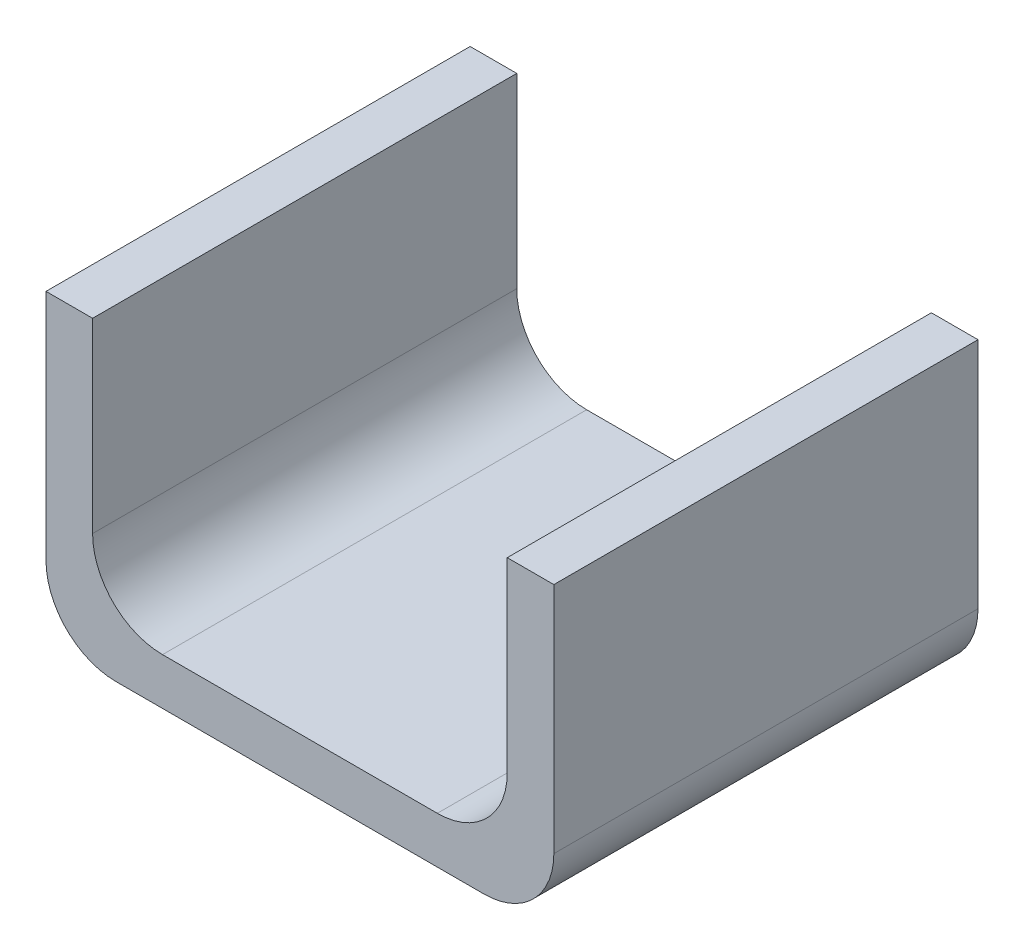
from build123d import *

# Parameters (mm, degrees)
SKETCH1_W           = 21.792403666
SKETCH1_H           = 18.201033873
BOSS_EXTRUDE1_DEPTH = 2
SKETCH1_3_W         = 2
SKETCH1_3_H         = 18.201033873
BOSS_EXTRUDE2_DEPTH = 13
FILLET1_R           = 3


with BuildPart() as part:
    # Sketch1 → Boss-Extrude1 (new body)
    with BuildSketch(Plane(origin=(0, 0, 0), x_dir=(1, 0, 0), z_dir=(0, 1, 0))):
        with Locations((-0.033894989, -2.255649147)):
            Rectangle(SKETCH1_W, SKETCH1_H)
    extrude(amount=BOSS_EXTRUDE1_DEPTH)

    # Sketch1_3 → Boss-Extrude2 (add)
    with BuildSketch(Plane(origin=(0, 0, 0), x_dir=(1, 0, 0), z_dir=(0, 1, 0))):
        with Locations((-9.930096822, -2.255649147)):
            Rectangle(SKETCH1_3_W, SKETCH1_3_H)
        with Locations((9.862306844, -2.255649147)):
            Rectangle(SKETCH1_3_W, SKETCH1_3_H)
    extrude(amount=BOSS_EXTRUDE2_DEPTH)

    # Fillet1
    fillet1_edges = [part.edges().sort_by_distance(p)[0] for p in [
        (-10.930096822, 0, 2.255649147),
        (10.862306844, 0, 2.255649147),
        (-8.930096822, 2, 2.255649147),
        (8.862306844, 2, 2.255649147),
    ]]
    fillet(fillet1_edges, radius=FILLET1_R)


solid = part.part
